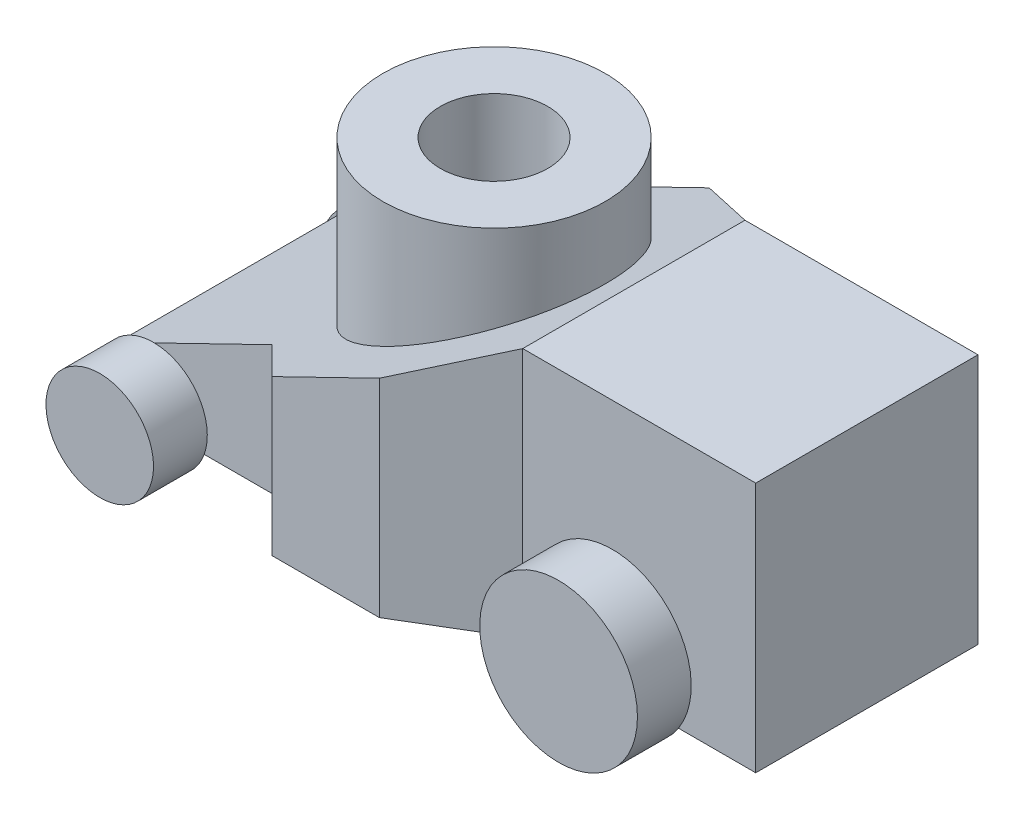
from build123d import *

# Parameters (mm, degrees)
EXTRUDE1_DEPTH      = 70
EXTRUDE2_DEPTH      = 70
EXTRUDE2_DEPTH_BACK = 90
SKETCH3_R           = 31
EXTRUDE3_DEPTH      = 86
EXTRUDE4_REACH      = 88
SKETCH4_R           = 15
SKETCH5_R           = 15
SKETCH5_R_2         = 22
EXTRUDE5_DEPTH      = 15


with BuildPart() as part:
    # Sketch1 → Extrude1 (new body)
    with BuildSketch(Plane(origin=(0, 0, 0), x_dir=(1, 0, 0), z_dir=(0, 1, 0))):
        Polygon((178, 31), (178, -31), (113, -31), (88, -46), (58, -46), (43, -31), (0, -31), (0, 31), (43, 31), (58, 46), (88, 46), (113, 31), align=None)
    extrude(amount=EXTRUDE1_DEPTH)

    # Sketch2 → Extrude2 (cut, two sides)
    with BuildSketch(Plane.XY.offset(31)) as extrude2_sk:
        Polygon((113, 70), (0, 70), (0, 15), align=None)
    extrude(amount=EXTRUDE2_DEPTH, mode=Mode.SUBTRACT)
    extrude(extrude2_sk.sketch, amount=-EXTRUDE2_DEPTH_BACK, mode=Mode.SUBTRACT)

    # Sketch3 → Extrude3 (add)
    with BuildSketch(Plane(origin=(0, 0, 0), x_dir=(1, 0, 0), z_dir=(0, 1, 0))):
        with Locations(Location((74, 0, 0), (0, 0, 180))):  # turned: the seam where the file's is
            Circle(SKETCH3_R)
    extrude(amount=EXTRUDE3_DEPTH)

    # Extrude4: up to this plane
    extrude4_end = Plane(origin=(113, 70, 101), z_dir=(-0.43763961, 0.899150472, 0))
    # Sketch4 → Extrude4 (cut, up to the surface)
    with BuildSketch(Plane(origin=(0, 86, 0), x_dir=(1, 0, 0), z_dir=(0, 1, 0)), mode=Mode.PRIVATE) as extrude4_sk1:
        with Locations(Location((74, 0, 0), (0, 0, 270))):  # turned: the seam where the file's is
            Circle(SKETCH4_R)
    extrude4_tool1 = split(extrude(extrude4_sk1.sketch, amount=-EXTRUDE4_REACH, mode=Mode.PRIVATE), bisect_by=extrude4_end, keep=Keep.BOTH, mode=Mode.PRIVATE)
    add(extrude4_tool1.solids().sort_by_distance((74, 86, 0))[0], mode=Mode.SUBTRACT)

    # Sketch5 → Extrude5 (add)
    with BuildSketch(Plane.XY.offset(31)):
        with Locations(Location((10, 5, 0), (0, 0, 88.976968381))):  # turned: the seam where the file's is
            Circle(SKETCH5_R)
        with Locations(Location((138, 12, 0), (0, 0, 213.055731151))):  # turned: the seam where the file's is
            Circle(SKETCH5_R_2)
    extrude5 = extrude(amount=EXTRUDE5_DEPTH)

    # Mirror1: Extrude5 across plane
    add(extrude5.mirror(Plane.XY))


solid = part.part
